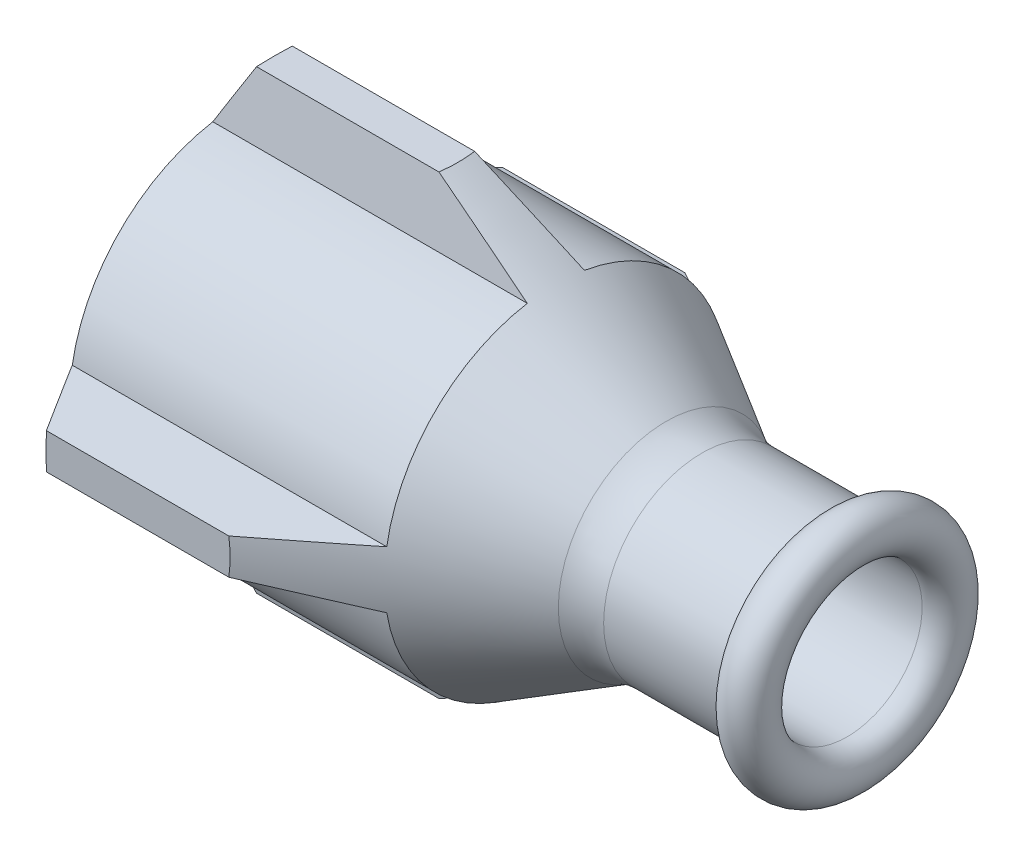
from build123d import *

# Parameters (mm, degrees)
CUT_EXTRUDE9_DEPTH  = 45.0000001
CUT_EXTRUDE10_REACH = 36.558
SKETCH8_R           = 1.5


with BuildPart() as part:
    # Sketch1 → Revolve1 (revolve)
    with BuildSketch(Plane(origin=(0, 0, 0), x_dir=(1, 0, 0), z_dir=(0, 1, 0))):
        with BuildLine():
            Line((0, 12), (0, 10.75))
            Line((0, 10.75), (3.5, 10.75))
            Line((3.5, 10.75), (18.5, 10.75))
            Line((18.5, 10.75), (20.5, 10.75))
            Line((20.5, 10.75), (24.5, 8.5))
            Line((24.5, 8.5), (26.5, 8.5))
            Line((26.5, 8.5), (26.5, 5.25))
            Line((26.5, 5.25), (42.375, 5.25))
            ThreePointArc((42.375, 5.25), (43.524048519, 8.024048519), (40.75, 6.875))
            Line((40.75, 6.875), (32.216506351, 6.875))
            ThreePointArc((32.216506351, 6.875), (30.922411125, 7.045370869), (29.716506351, 7.544872981))
            Line((29.716506351, 7.544872981), (28.062177826, 8.5))
            Line((28.062177826, 8.5), (22, 12))
            Line((22, 12), (0, 12))
        make_face()
    revolve(axis=Axis((-40.558590026, 0, 0), (1, 0, 0)))

    # Sketch5 → Revolve2 (revolve)
    with BuildSketch(Plane.XY):
        Polygon((22, -12), (15.07179677, -16), (2.309401077, -16), (0, -12), align=None)
    revolve(axis=Axis((-0.804180618, 0, 0), (1, 0, 0)))

    # Sketch7 → Cut-Extrude9 (cut, through all)
    with BuildSketch(Plane(origin=(0, 0, 0), x_dir=(0, 0, -1), z_dir=(1, 0, 0))):
        with BuildLine():
            ThreePointArc((1.25, 15.951097141), (0, 16), (-1.25, 15.951097141))
            Line((-1.25, 15.951097141), (1.25, 15.951097141))
        make_face()
        with BuildLine():
            Line((-11.832293992, -1.999204566), (-15.951097141, -1.25))
            ThreePointArc((-15.951097141, -1.25), (-11.313708499, -11.313708499), (-1.25, -15.951097141))
            Line((-1.25, -15.951097141), (-2, -11.832159566))
            ThreePointArc((-2, -11.832159566), (-8.485566586, -8.484996153), (-11.832293992, -1.999204566))
        make_face()
        with BuildLine():
            ThreePointArc((15.951097141, 1.25), (11.313708499, 11.313708499), (1.25, 15.951097141))
            Line((1.25, 15.951097141), (2, 11.832159566))
            ThreePointArc((2, 11.832159566), (8.485566586, 8.484996153), (11.832293992, 1.999204566))
            Line((11.832293992, 1.999204566), (15.951097141, 1.25))
        make_face()
        with BuildLine():
            Line((-15.951097141, 1.25), (-11.832159566, 2))
            ThreePointArc((-11.832159566, 2), (-8.484996153, 8.485566586), (-1.999204566, 11.832293992))
            Line((-1.999204566, 11.832293992), (-1.25, 15.951097141))
            ThreePointArc((-1.25, 15.951097141), (-11.313708499, 11.313708499), (-15.951097141, 1.25))
        make_face()
        with BuildLine():
            Line((1.999204566, -11.832293992), (1.25, -15.951097141))
            ThreePointArc((1.25, -15.951097141), (11.313708499, -11.313708499), (15.951097141, -1.25))
            Line((15.951097141, -1.25), (11.832159566, -2))
            ThreePointArc((11.832159566, -2), (8.484996153, -8.485566586), (1.999204566, -11.832293992))
        make_face()
        with BuildLine():
            Line((1.25, -15.951097141), (-1.25, -15.951097141))
            ThreePointArc((-1.25, -15.951097141), (0, -16), (1.25, -15.951097141))
        make_face()
        with BuildLine():
            Line((-15.951097141, -1.25), (-15.951097141, 1.25))
            ThreePointArc((-15.951097141, 1.25), (-16, 0), (-15.951097141, -1.25))
        make_face()
        with BuildLine():
            ThreePointArc((16, 0), (15.987769611, 0.625478115), (15.951097141, 1.25))
            Line((15.951097141, 1.25), (15.951097141, -1.25))
            ThreePointArc((15.951097141, -1.25), (15.987769611, -0.625478115), (16, 0))
        make_face()
    extrude(amount=CUT_EXTRUDE9_DEPTH, mode=Mode.SUBTRACT)

    # Sketch8 → Cut-Extrude10 (cut, up to next)
    with BuildSketch(Plane(origin=(0, -8.485281374, -8.485281374), x_dir=(1, 0, 0), z_dir=(0, 0.707106781, 0.707106781)), mode=Mode.PRIVATE) as cut_extrude10_sk1:
        with Locations((6, 0)):
            Circle(SKETCH8_R)
    cut_extrude10_tool1 = extrude(cut_extrude10_sk1.sketch, amount=CUT_EXTRUDE10_REACH, mode=Mode.PRIVATE) & part.part
    add(cut_extrude10_tool1.solids().sort_by_distance((6, -8.485281, -8.485281))[0], mode=Mode.SUBTRACT)


solid = part.part
